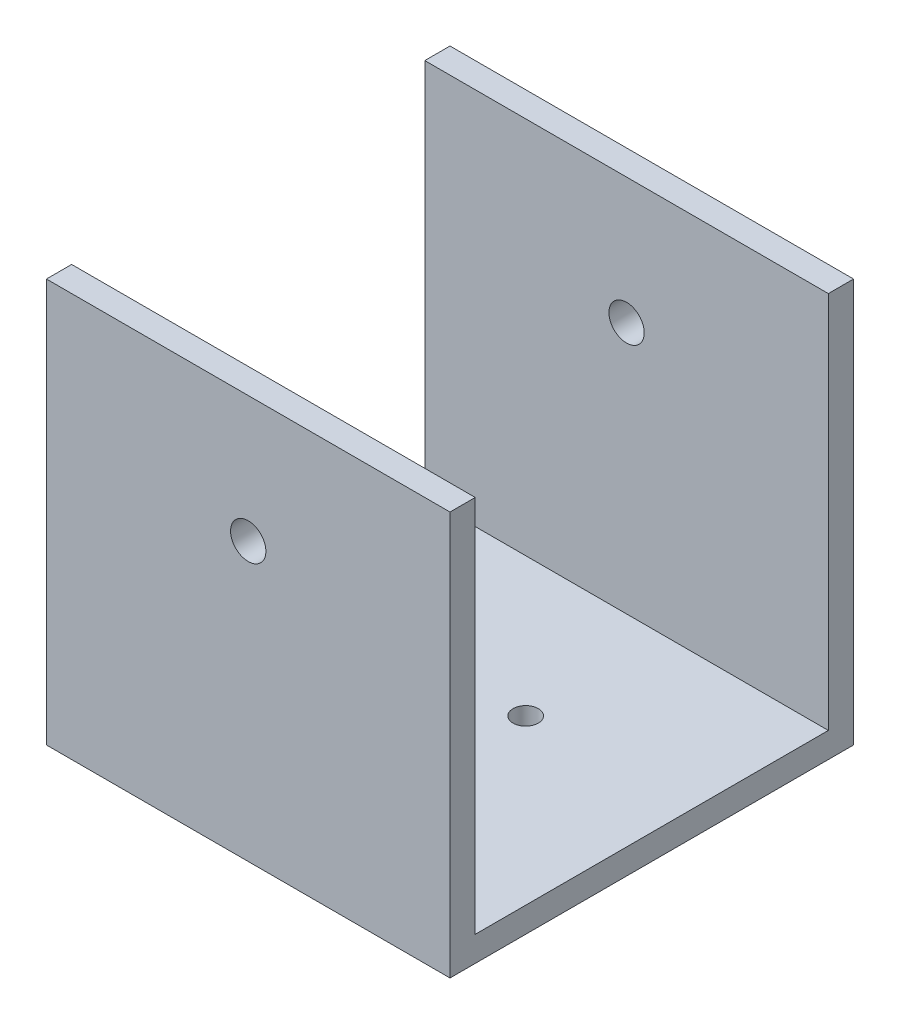
from build123d import *

# Parameters (mm, degrees)
SKETCH1_W           = 80
SKETCH1_H           = 80
SKETCH1_R           = 3.5
BOSS_EXTRUDE1_DEPTH = 80
SKETCH2_W           = 70
SKETCH2_H           = 75
CUT_EXTRUDE1_DEPTH  = 80
SKETCH3_R           = 2.5
CUT_EXTRUDE2_DEPTH  = 60


with BuildPart() as part:
    # Sketch1 → Boss-Extrude1 (new body)
    with BuildSketch(Plane.XY):
        Rectangle(SKETCH1_W, SKETCH1_H)
        with Locations((0, 15)):
            Circle(SKETCH1_R, mode=Mode.SUBTRACT)
    extrude(amount=BOSS_EXTRUDE1_DEPTH)

    # Sketch2 → Cut-Extrude1 (cut)
    with BuildSketch(Plane(origin=(40, 0, 0), x_dir=(0, 0, -1), z_dir=(1, 0, 0))):
        with Locations((-40, 2.5)):
            Rectangle(SKETCH2_W, SKETCH2_H)
    extrude(amount=-CUT_EXTRUDE1_DEPTH, mode=Mode.SUBTRACT)

    # Sketch3 → Cut-Extrude2 (cut)
    with BuildSketch(Plane.XZ.offset(40)):
        with Locations((-27.5, 67.5)):
            Circle(SKETCH3_R)
        with Locations((7.5, 67.5)):
            Circle(SKETCH3_R)
        with Locations((7.5, 32.5)):
            Circle(SKETCH3_R)
        with Locations((-27.5, 32.5)):
            Circle(SKETCH3_R)
    extrude(amount=-CUT_EXTRUDE2_DEPTH, mode=Mode.SUBTRACT)


solid = part.part
